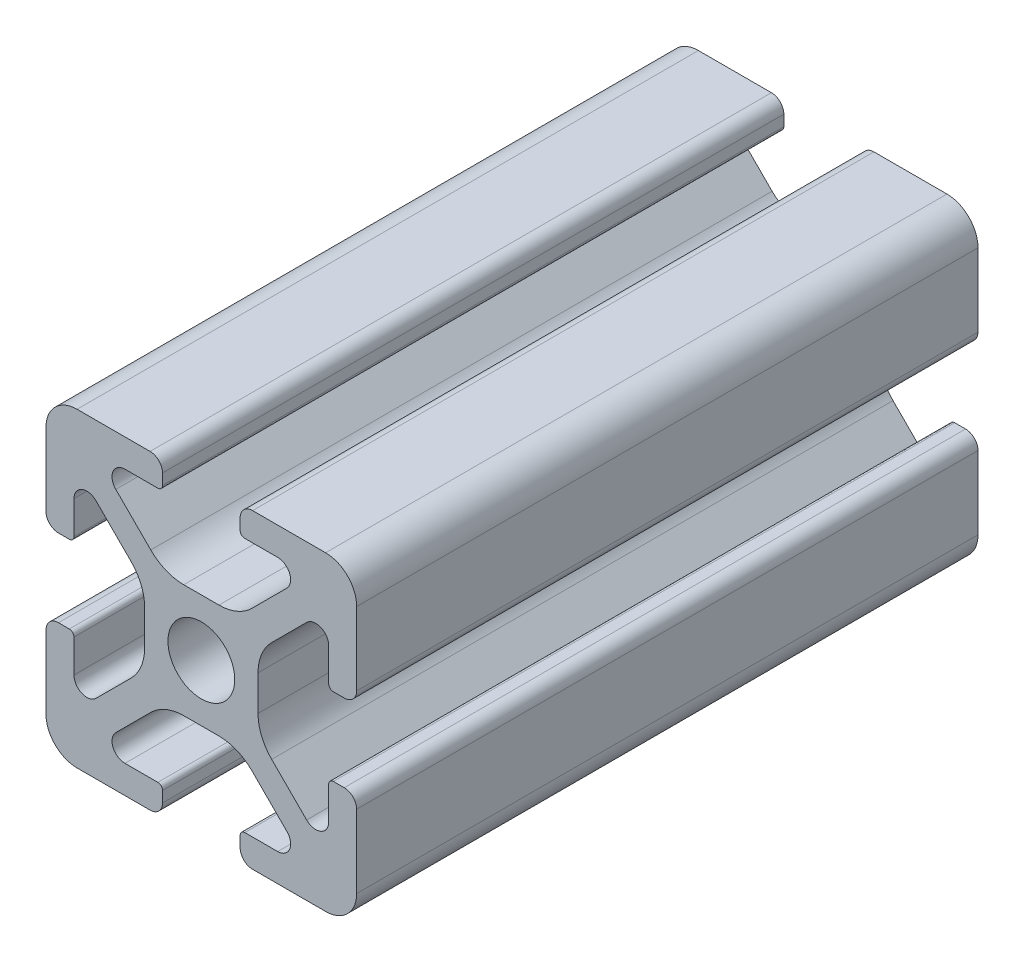
from build123d import *

# Parameters (mm, degrees)
SKETCH1_R           = 2.15
BOSS_EXTRUDE1_DEPTH = 40


with BuildPart() as part:
    # Sketch1 → Boss-Extrude1 (new body)
    with BuildSketch(Plane(origin=(0, 0, 0), x_dir=(-1, 0, 0), z_dir=(0, 0, -1))):
        with BuildLine():
            Line((-12.499999997, 0.800000003), (-12.499999998, 1.500000003))
            ThreePointArc((-12.499999998, 1.500000003), (-12.587867964, 1.712132039), (-12.8, 1.800000005))
            Line((-12.8, 1.800000005), (-14.9175884, 1.800000005))
            ThreePointArc((-14.9175884, 1.800000005), (-15.686636445, 2.313861481), (-15.506192291, 3.221015502))
            Line((-15.506192291, 3.221015502), (-13.255887451, 5.471320342))
            ThreePointArc((-13.255887451, 5.471320342), (-12.282617405, 6.121638595), (-11.134567109, 6.349999998))
            Line((-11.134567109, 6.349999998), (-8.865432906, 6.349999998))
            ThreePointArc((-8.865432906, 6.349999998), (-7.717382611, 6.121638596), (-6.744112565, 5.471320342))
            Line((-6.744112565, 5.471320342), (-4.493807727, 3.221015504))
            ThreePointArc((-4.493807727, 3.221015504), (-4.313363573, 2.313861481), (-5.082411619, 1.800000005))
            Line((-5.082411619, 1.800000005), (-7.20000001, 1.800000005))
            ThreePointArc((-7.20000001, 1.800000005), (-7.412132045, 1.71213204), (-7.50000001, 1.500000005))
            Line((-7.50000001, 1.500000005), (-7.50000001, 0.8))
            ThreePointArc((-7.50000001, 0.8), (-7.265685435, 0.234314575), (-6.70000001, 0))
            Line((-6.70000001, 0), (-2, 0))
            ThreePointArc((-2, 0), (-0.585786438, 0.585786438), (0, 2))
            Line((0, 2), (0, 6.699999998))
            ThreePointArc((0, 6.699999998), (-0.234314576, 7.265685424), (-0.800000003, 7.5))
            Line((-0.800000003, 7.5), (-1.500000007, 7.5))
            ThreePointArc((-1.500000007, 7.5), (-1.712132044, 7.412132033), (-1.80000001, 7.199999997))
            Line((-1.80000001, 7.199999997), (-1.80000001, 5.082411604))
            ThreePointArc((-1.80000001, 5.082411604), (-2.313861485, 4.313363559), (-3.221015507, 4.493807713))
            Line((-3.221015507, 4.493807713), (-5.471320347, 6.744112553))
            ThreePointArc((-5.471320347, 6.744112553), (-6.1216386, 7.717382599), (-6.350000003, 8.865432896))
            Line((-6.350000003, 8.865432896), (-6.350000003, 11.134567105))
            ThreePointArc((-6.350000003, 11.134567105), (-6.121638601, 12.2826174), (-5.471320347, 13.255887446))
            Line((-5.471320347, 13.255887446), (-3.221015511, 15.506192282))
            ThreePointArc((-3.221015511, 15.506192282), (-2.313861487, 15.686636436), (-1.80000001, 14.917588389))
            Line((-1.80000001, 14.917588389), (-1.80000001, 12.799999998))
            ThreePointArc((-1.80000001, 12.799999998), (-1.712132045, 12.587867963), (-1.50000001, 12.499999997))
            Line((-1.50000001, 12.499999997), (-0.8, 12.499999997))
            ThreePointArc((-0.8, 12.499999997), (-0.234314575, 12.734314573), (0, 13.299999998))
            Line((0, 13.299999998), (0, 18))
            ThreePointArc((0, 18), (-0.585786438, 19.414213562), (-2, 20))
            Line((-2, 20), (-6.700000008, 20))
            ThreePointArc((-6.700000008, 20), (-7.265685435, 19.765685424), (-7.50000001, 19.199999998))
            Line((-7.50000001, 19.199999998), (-7.50000001, 18.500000005))
            ThreePointArc((-7.50000001, 18.500000005), (-7.412132044, 18.287867969), (-7.200000008, 18.200000003))
            Line((-7.200000008, 18.200000003), (-5.082411595, 18.200000003))
            ThreePointArc((-5.082411595, 18.200000003), (-4.313363547, 17.686138525), (-4.493807702, 16.7789845))
            Line((-4.493807702, 16.7789845), (-6.744112543, 14.528679659))
            ThreePointArc((-6.744112543, 14.528679659), (-7.717382589, 13.878361405), (-8.865432885, 13.650000003))
            Line((-8.865432885, 13.650000003), (-11.134567111, 13.650000003))
            ThreePointArc((-11.134567111, 13.650000003), (-12.282617406, 13.878361405), (-13.255887452, 14.528679658))
            Line((-13.255887452, 14.528679658), (-15.506192292, 16.778984498))
            ThreePointArc((-15.506192292, 16.778984498), (-15.686636447, 17.686138525), (-14.917588397, 18.200000002))
            Line((-14.917588397, 18.200000002), (-12.799999998, 18.200000003))
            ThreePointArc((-12.799999998, 18.200000003), (-12.587867963, 18.287867968), (-12.499999997, 18.500000002))
            Line((-12.499999997, 18.500000002), (-12.499999997, 19.2))
            ThreePointArc((-12.499999997, 19.2), (-12.734314573, 19.765685425), (-13.299999998, 20))
            Line((-13.299999998, 20), (-18, 20))
            ThreePointArc((-18, 20), (-19.414213562, 19.414213562), (-20, 18))
            Line((-20, 18), (-20, 13.3))
            ThreePointArc((-20, 13.3), (-19.765685424, 12.734314573), (-19.199999998, 12.499999997))
            Line((-19.199999998, 12.499999997), (-18.500000003, 12.499999997))
            ThreePointArc((-18.500000003, 12.499999997), (-18.287867967, 12.587867964), (-18.2, 12.8))
            Line((-18.2, 12.8), (-18.2, 14.91758839))
            ThreePointArc((-18.2, 14.91758839), (-17.686138525, 15.686636435), (-16.778984504, 15.506192281))
            Line((-16.778984504, 15.506192281), (-14.528679657, 13.255887434))
            ThreePointArc((-14.528679657, 13.255887434), (-13.878361403, 12.282617388), (-13.65, 11.134567091))
            Line((-13.65, 11.134567091), (-13.65, 8.865432887))
            ThreePointArc((-13.65, 8.865432887), (-13.878361403, 7.717382591), (-14.528679656, 6.744112546))
            Line((-14.528679656, 6.744112546), (-16.778984496, 4.493807706))
            ThreePointArc((-16.778984496, 4.493807706), (-17.686138522, 4.313363551), (-18.2, 5.0824116))
            Line((-18.2, 5.0824116), (-18.2, 7.2))
            ThreePointArc((-18.2, 7.2), (-18.287867966, 7.412132034), (-18.5, 7.5))
            Line((-18.5, 7.5), (-19.2, 7.5))
            ThreePointArc((-19.2, 7.5), (-19.765685425, 7.265685425), (-20, 6.7))
            Line((-20, 6.7), (-20, 2))
            ThreePointArc((-20, 2), (-19.414213562, 0.585786438), (-18, 0))
            Line((-18, 0), (-13.3, 0))
            ThreePointArc((-13.3, 0), (-12.734314573, 0.234314576), (-12.499999997, 0.800000003))
        make_face()
        with Locations((-10, 10)):
            Circle(SKETCH1_R, mode=Mode.SUBTRACT)
    extrude(amount=-BOSS_EXTRUDE1_DEPTH)


solid = part.part
